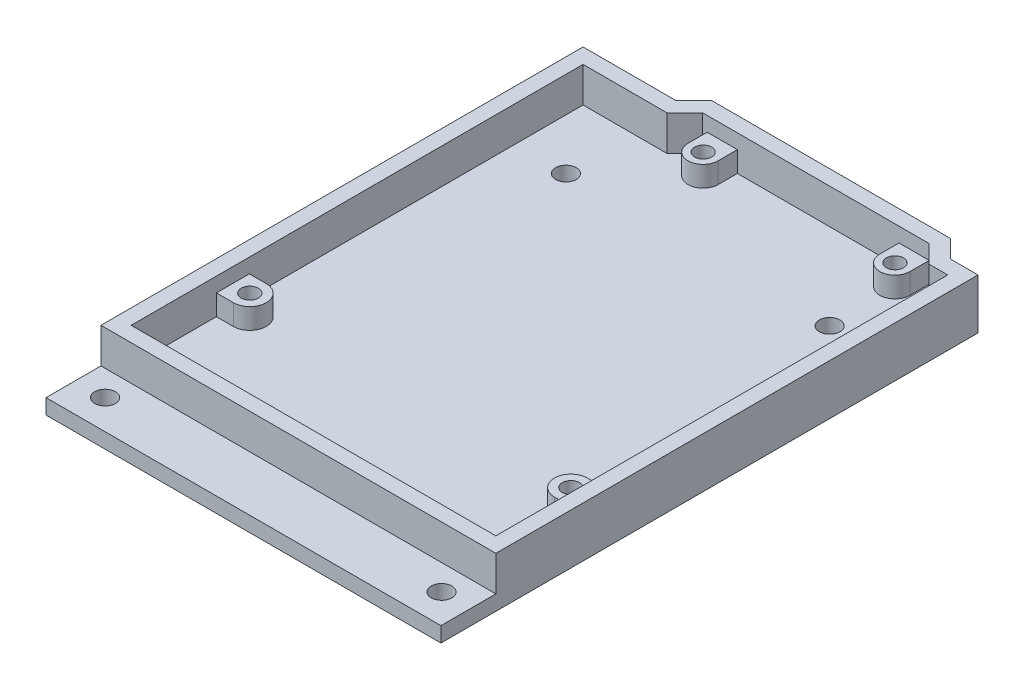
from build123d import *

# Parameters (mm, degrees)
BOSS_EXTRUDE1_DEPTH = 2.2
EXTRUDE_THIN1_DEPTH = 5.12
BOSS_EXTRUDE2_DEPTH = 3
SKETCH6_R           = 1.25
SKETCH6_R_2         = 1.5
CUT_EXTRUDE1_DEPTH  = 8.32


with BuildPart() as part:
    # Sketch1 → Boss-Extrude1 (new body)
    with BuildSketch(Plane(origin=(0, 0, 0), x_dir=(1, 0, 0), z_dir=(0, 1, 0))):
        Polygon((-15.25, 39.1), (-12.65, 41.7), (22.15, 41.7), (24.75, 39.1), (28.75, 39.1), (28.75, -39.1), (-28.75, -39.1), (-28.75, 39.1), align=None)
    extrude(amount=BOSS_EXTRUDE1_DEPTH)

    # Sketch3 → Extrude-Thin1 (add)
    with BuildSketch(Plane(origin=(0, 2.2, 0), x_dir=(1, 0, 0), z_dir=(0, 1, 0))):
        Polygon((-28.75, 39.1), (-15.25, 39.1), (-12.65, 41.7), (22.15, 41.7), (24.75, 39.1), (28.75, 39.1), (28.75, -31.1), (-28.75, -31.1), align=None)
        Polygon((-26.55, 36.9), (-14.338730163, 36.9), (-11.738730163, 39.5), (21.238730163, 39.5), (23.838730163, 36.9), (26.55, 36.9), (26.55, -28.9), (-26.55, -28.9), align=None, mode=Mode.SUBTRACT)
    extrude(amount=EXTRUDE_THIN1_DEPTH)

    # Sketch4 → Boss-Extrude2 (add)
    with BuildSketch(Plane(origin=(0, 2.2, 0), x_dir=(1, 0, 0), z_dir=(0, 1, 0))):
        with BuildLine():
            Line((-11.08, 39.5), (-6.68, 39.5))
            Line((-6.68, 39.5), (-6.68, 36.7))
            ThreePointArc((-6.68, 36.7), (-8.88, 34.5), (-11.08, 36.7))
            Line((-11.08, 36.7), (-11.08, 39.5))
        make_face()
        with BuildLine():
            Line((16.85, 39.5), (21.25, 39.5))
            Line((21.25, 39.5), (21.25, 36.7))
            ThreePointArc((21.25, 36.7), (19.05, 34.5), (16.85, 36.7))
            Line((16.85, 36.7), (16.85, 39.5))
        make_face()
        with BuildLine():
            Line((26.55, -12.83), (23.8, -12.83))
            ThreePointArc((23.8, -12.83), (21.4, -15.23), (23.8, -17.63))
            Line((23.8, -17.63), (26.55, -17.63))
            Line((26.55, -17.63), (26.55, -12.83))
        make_face()
        with BuildLine():
            Line((-26.55, -11.69), (-24.086432316, -11.69))
            ThreePointArc((-24.086432316, -11.69), (-21.686432316, -14.09), (-24.086432316, -16.49))
            Line((-24.086432316, -16.49), (-26.55, -16.49))
            Line((-26.55, -16.49), (-26.55, -11.69))
        make_face()
    extrude(amount=BOSS_EXTRUDE2_DEPTH)

    # Sketch6 → Cut-Extrude1 (cut, through all)
    with BuildSketch(Plane(origin=(0, 7.32, 0), x_dir=(1, 0, 0), z_dir=(0, 1, 0))):
        with Locations((-8.88, 36.7)):
            Circle(SKETCH6_R)
        with Locations((19.05, 36.7)):
            Circle(SKETCH6_R)
        with Locations((23.8, -15.23)):
            Circle(SKETCH6_R)
        with Locations((-24.086432316, -14.09)):
            Circle(SKETCH6_R)
        with Locations((-19.15, 27)):
            Circle(SKETCH6_R_2)
        with Locations((19.25, 27)):
            Circle(SKETCH6_R_2)
        with Locations((-24.45, -34.8)):
            Circle(SKETCH6_R_2)
        with Locations((24.55, -34.8)):
            Circle(SKETCH6_R_2)
    extrude(amount=-CUT_EXTRUDE1_DEPTH, mode=Mode.SUBTRACT)


solid = part.part
